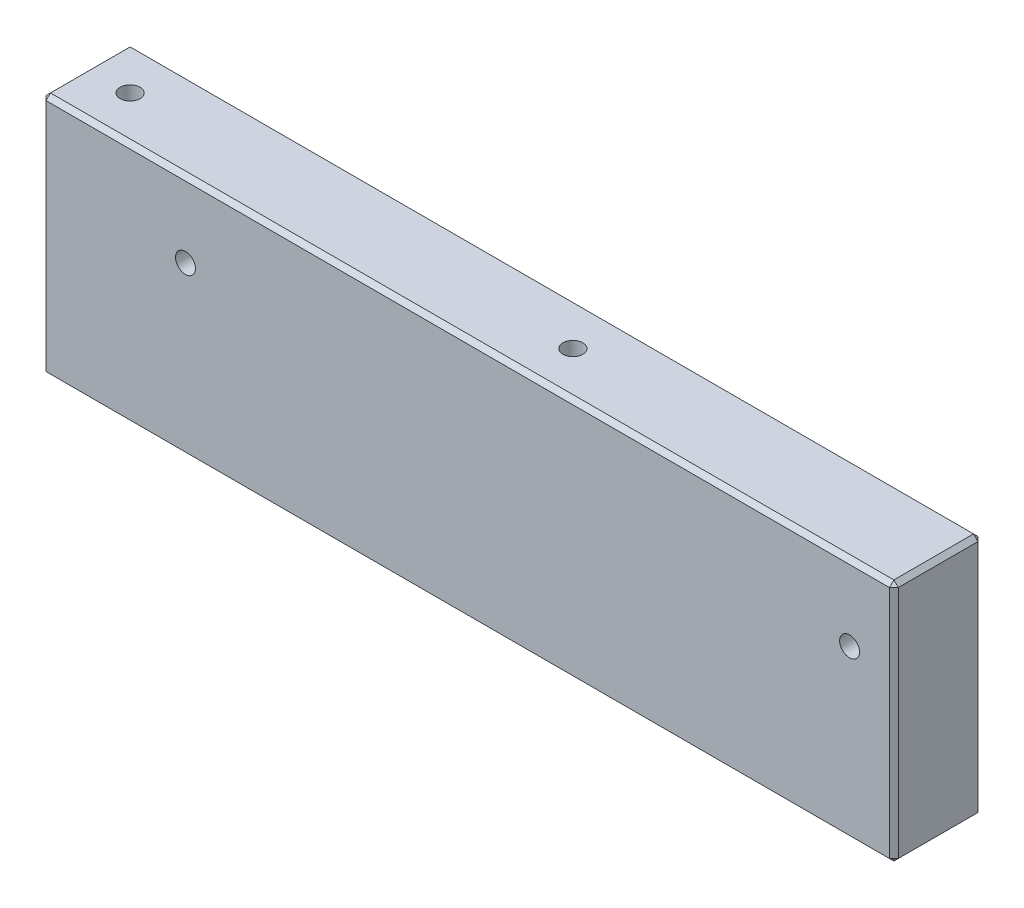
from build123d import *

# Parameters (mm, degrees)
SKETCH1_W                                        = 192.5
SKETCH1_H                                        = 55
BOSS_EXTRUDE1_DEPTH                              = 20
CBORE_FOR_M4_HEX_HEAD_MACHINE_SCREW1_D           = 4.5
CBORE_FOR_M4_HEX_HEAD_MACHINE_SCREW1_DEPTH       = 55
CBORE_FOR_M4_HEX_HEAD_MACHINE_SCREW1_CBORE_D     = 9
CBORE_FOR_M4_HEX_HEAD_MACHINE_SCREW1_CBORE_DEPTH = 50
CBORE_FOR_M4_HEX_HEAD_MACHINE_SCREW2_D           = 4.5
CBORE_FOR_M4_HEX_HEAD_MACHINE_SCREW2_DEPTH       = 20
CBORE_FOR_M4_HEX_HEAD_MACHINE_SCREW2_CBORE_D     = 9
CBORE_FOR_M4_HEX_HEAD_MACHINE_SCREW2_CBORE_DEPTH = 5
CHAMFER1_SIZE                                    = 1


with BuildPart() as part:
    # Sketch1 → Boss-Extrude1 (new body)
    with BuildSketch(Plane(origin=(0, 0, 0), x_dir=(-1, 0, 0), z_dir=(0, 0, -1))):
        with Locations((-96.25, 27.5)):
            Rectangle(SKETCH1_W, SKETCH1_H)
    extrude(amount=-BOSS_EXTRUDE1_DEPTH)

    # CBORE for M4 Hex Head Machine Screw1
    with Locations(Plane(origin=(0, 0, 0), x_dir=(-1, 0, 0), z_dir=(0, -1, 0))):
        with Locations((-110, -10), (-10, -10)):
            CounterBoreHole(CBORE_FOR_M4_HEX_HEAD_MACHINE_SCREW1_D / 2, CBORE_FOR_M4_HEX_HEAD_MACHINE_SCREW1_CBORE_D / 2, CBORE_FOR_M4_HEX_HEAD_MACHINE_SCREW1_CBORE_DEPTH, depth=CBORE_FOR_M4_HEX_HEAD_MACHINE_SCREW1_DEPTH)

    # CBORE for M4 Hex Head Machine Screw2
    with Locations(Plane(origin=(0, 0, 0), x_dir=(-1, 0, 0), z_dir=(0, 0, -1))):
        with Locations((-182.5, 38), (-32.5, 38)):
            CounterBoreHole(CBORE_FOR_M4_HEX_HEAD_MACHINE_SCREW2_D / 2, CBORE_FOR_M4_HEX_HEAD_MACHINE_SCREW2_CBORE_D / 2, CBORE_FOR_M4_HEX_HEAD_MACHINE_SCREW2_CBORE_DEPTH, depth=CBORE_FOR_M4_HEX_HEAD_MACHINE_SCREW2_DEPTH)

    # Chamfer1
    chamfer1_edges = [part.edges().sort_by_distance(p)[0] for p in [
        (192.5, 27.5, 20),
        (96.25, 0, 20),
        (0, 27.5, 20),
        (96.25, 0, 0),
        (192.5, 27.5, 0),
        (96.25, 55, 0),
        (0, 27.5, 0),
        (0, 0, 10),
        (192.5, 0, 10),
        (192.5, 55, 10),
        (0, 55, 10),
        (96.25, 55, 20),
    ]]
    chamfer(chamfer1_edges, length=CHAMFER1_SIZE)


solid = part.part
